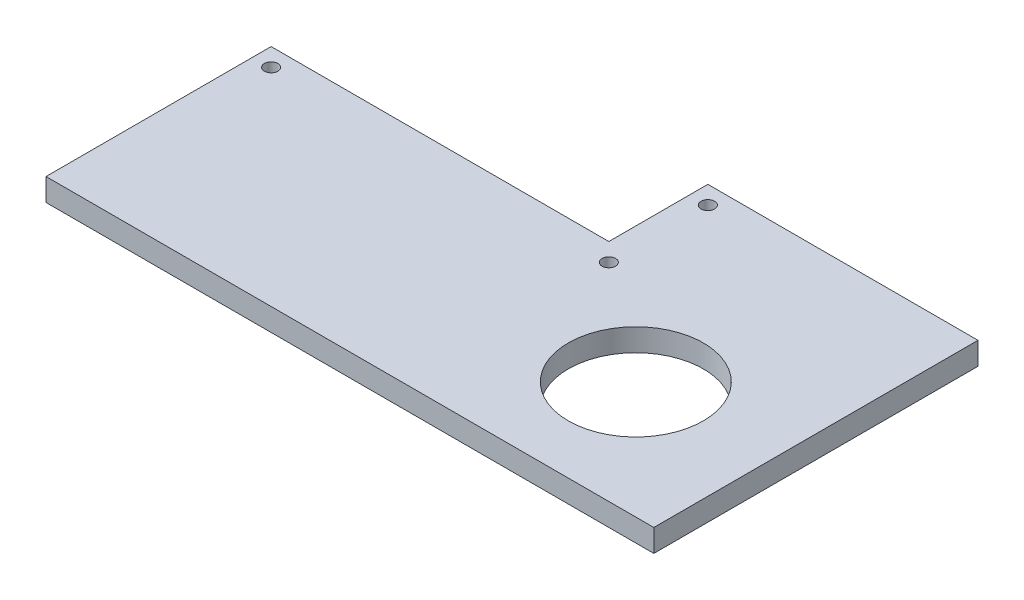
from build123d import *

# Parameters (mm, degrees)
SKETCH1_R           = 1.5
SKETCH1_R_2         = 15
BOSS_EXTRUDE1_DEPTH = 5


with BuildPart() as part:
    # Sketch1 → Boss-Extrude1 (new body)
    with BuildSketch(Plane(origin=(0, 0, 0), x_dir=(1, 0, 0), z_dir=(0, 1, 0))):
        Polygon((-41.5, -7), (33.5, -7), (33.5, 15), (93.5, 15), (93.5, -57), (-41.5, -57), align=None)
        with Locations((-37.5, -11)):
            Circle(SKETCH1_R, mode=Mode.SUBTRACT)
        with Locations((37.5, -11)):
            Circle(SKETCH1_R, mode=Mode.SUBTRACT)
        with Locations((37.5, 11)):
            Circle(SKETCH1_R, mode=Mode.SUBTRACT)
        with Locations((63.5, -31)):
            Circle(SKETCH1_R_2, mode=Mode.SUBTRACT)
    extrude(amount=BOSS_EXTRUDE1_DEPTH)


solid = part.part
